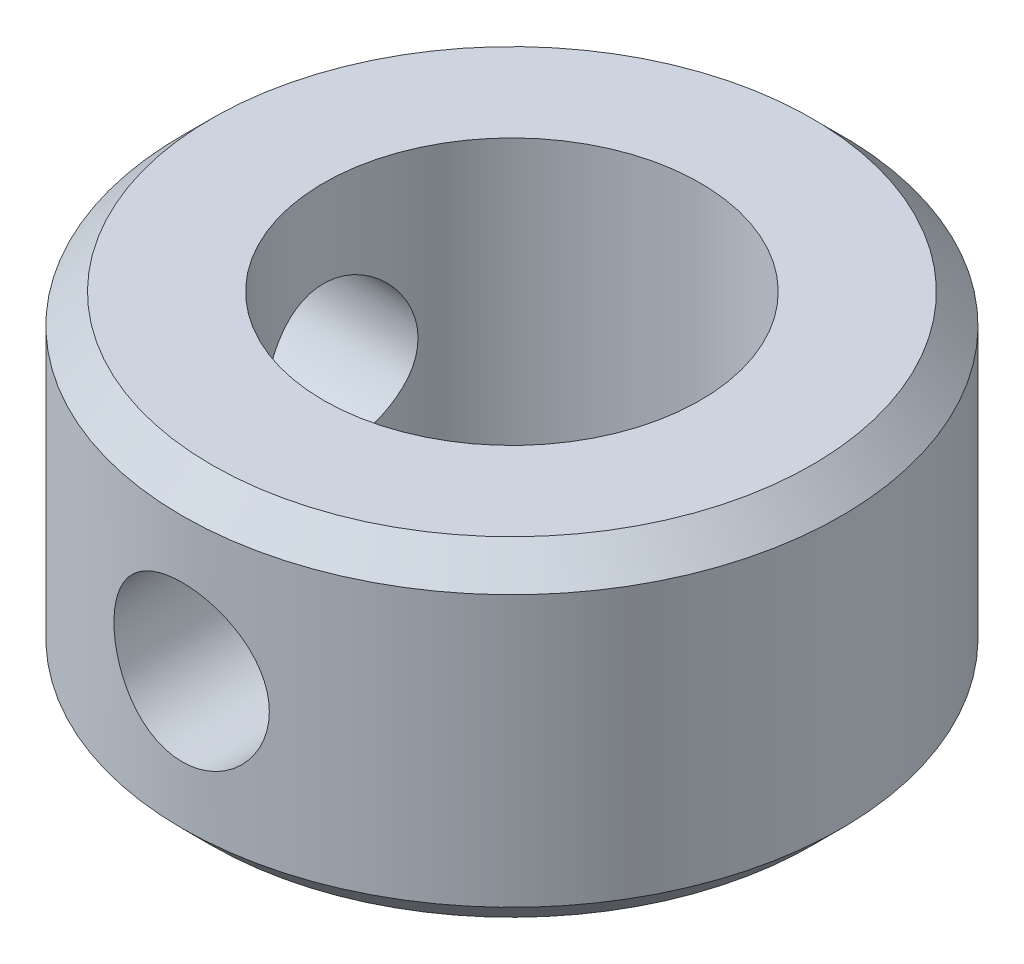
from build123d import *

# Parameters (mm, degrees)
SKETCH1_R                  = 7
SKETCH1_R_2                = 4
BOSS_EXTRUDE1_DEPTH        = 3.5
M4X0_7_TAPPED_HOLE1_REACH  = 18.039
M4X0_7_TAPPED_HOLE1_BORE_R = 1.65
CHAMFER1_SIZE              = 0.625
CIRPATTERN1_COUNT          = 2
CIRPATTERN1_ANGLE          = 90


with BuildPart() as part:
    # Sketch1 → Boss-Extrude1 (new, symmetric)
    with BuildSketch(Plane(origin=(0, 0, 0), x_dir=(1, 0, 0), z_dir=(0, 1, 0))):
        with Locations(Location((0, 0, 0), (0, 0, 270))):
            Circle(SKETCH1_R)
        with Locations(Location((0, 0, 0), (0, 0, 270))):
            Circle(SKETCH1_R_2, mode=Mode.SUBTRACT)
    extrude(amount=BOSS_EXTRUDE1_DEPTH, both=True)

    # M4x0.7 Tapped Hole1 bore → M4x0.7 Tapped Hole1 (cut, up to next)
    with BuildSketch(Plane.XY.offset(7), mode=Mode.PRIVATE) as m4x0_7_tapped_hole1_sk1:
        Circle(M4X0_7_TAPPED_HOLE1_BORE_R)
    m4x0_7_tapped_hole1_tool1 = extrude(m4x0_7_tapped_hole1_sk1.sketch, amount=-M4X0_7_TAPPED_HOLE1_REACH, mode=Mode.PRIVATE) & part.part
    m4x0_7_tapped_hole1 = m4x0_7_tapped_hole1_tool1.solids().sort_by_distance((0, 0, 7))[0]
    add(m4x0_7_tapped_hole1, mode=Mode.SUBTRACT)

    # Chamfer1
    chamfer1_edges = [part.edges().sort_by_distance(p)[0] for p in [
        (0, -3.5, -7),
        (0, 3.5, -7),
    ]]
    chamfer(chamfer1_edges, length=CHAMFER1_SIZE)

    # CirPattern1: M4x0.7 Tapped Hole1 ×2 about axis
    cirpattern1_axis = Axis((0, 3.5, 0), (0, -1, 0))
    for i in range(1, CIRPATTERN1_COUNT):
        add(m4x0_7_tapped_hole1.rotate(cirpattern1_axis, i * CIRPATTERN1_ANGLE / (CIRPATTERN1_COUNT - 1)), mode=Mode.SUBTRACT)


solid = part.part
